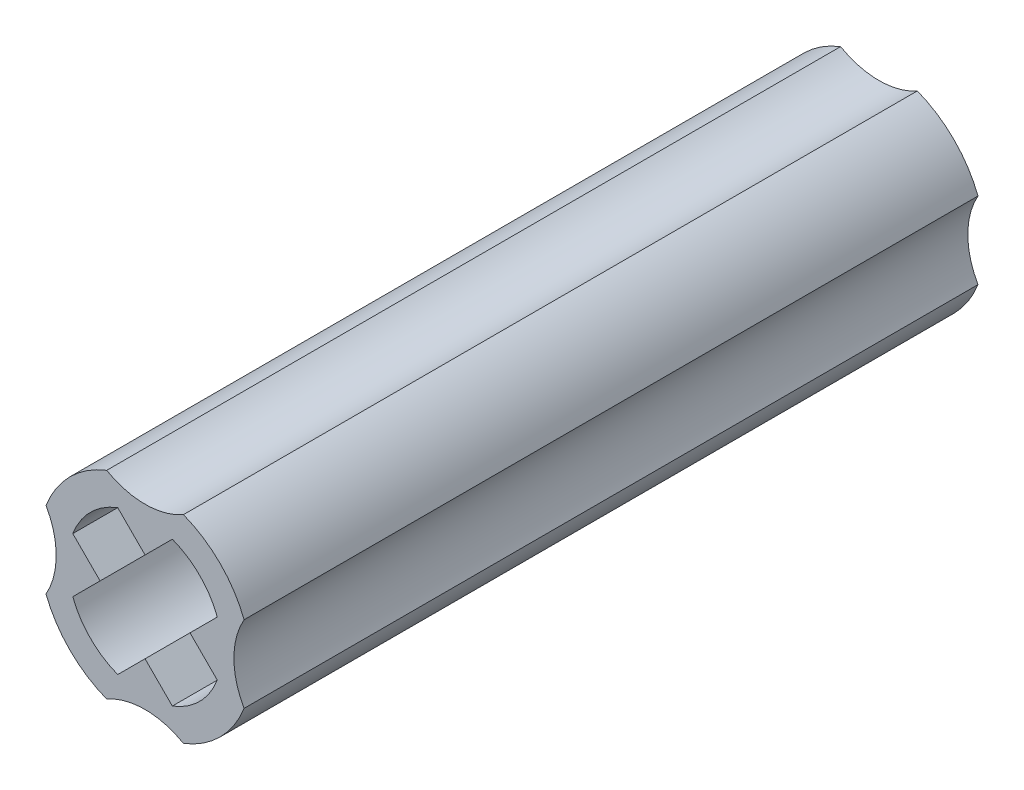
from build123d import *

# Parameters (mm, degrees)
BOSS_EXTRUDE1_DEPTH     = 12.065
CUT_EXTRUDE1_DEPTH      = 13.065
CUT_EXTRUDE1_DEPTH_BACK = 13.065
SKETCH3_R               = 2.54
SKETCH3_R_2             = 1.477926828
BOSS_EXTRUDE2_DEPTH     = 4.1275


with BuildPart() as part:
    # Sketch1 → Boss-Extrude1 (new body, symmetric)
    with BuildSketch(Plane.XY):
        with BuildLine():
            ThreePointArc((-3.256590116, -1.261814988), (-2.469570433, -2.469570433), (-1.261814988, -3.256590116))
            ThreePointArc((-1.261814988, -3.256590116), (0, -2.921), (1.261814988, -3.256590116))
            ThreePointArc((1.261814988, -3.256590116), (2.469570433, -2.469570433), (3.256590116, -1.261814988))
            ThreePointArc((3.256590116, -1.261814988), (2.921, 0), (3.256590116, 1.261814988))
            ThreePointArc((3.256590116, 1.261814988), (2.469570433, 2.469570433), (1.261814988, 3.256590116))
            ThreePointArc((1.261814988, 3.256590116), (0, 2.921), (-1.261814988, 3.256590116))
            ThreePointArc((-1.261814988, 3.256590116), (-2.469570433, 2.469570433), (-3.256590116, 1.261814988))
            ThreePointArc((-3.256590116, 1.261814988), (-2.921, 0), (-3.256590116, -1.261814988))
        make_face()
    extrude(amount=BOSS_EXTRUDE1_DEPTH, both=True)

    # Sketch2 → Cut-Extrude1 (cut, two sides)
    with BuildSketch(Plane.XY) as cut_extrude1_sk:
        with BuildLine():
            Line((-0.898025612, 2.375952441), (0, 1.477926828))
            Line((0, 1.477926828), (0.898025612, 2.375952441))
            ThreePointArc((0.898025612, 2.375952441), (1.796051224, 1.796051224), (2.375952441, 0.898025612))
            Line((2.375952441, 0.898025612), (1.477926828, 0))
            Line((1.477926828, 0), (2.375952441, -0.898025612))
            ThreePointArc((2.375952441, -0.898025612), (1.796051224, -1.796051224), (0.898025612, -2.375952441))
            Line((0.898025612, -2.375952441), (0, -1.477926828))
            Line((0, -1.477926828), (-0.898025612, -2.375952441))
            ThreePointArc((-0.898025612, -2.375952441), (-1.796051224, -1.796051224), (-2.375952441, -0.898025612))
            Line((-2.375952441, -0.898025612), (-1.477926828, 0))
            Line((-1.477926828, 0), (-2.375952441, 0.898025612))
            ThreePointArc((-2.375952441, 0.898025612), (-1.796051224, 1.796051224), (-0.898025612, 2.375952441))
        make_face()
    extrude(amount=CUT_EXTRUDE1_DEPTH, mode=Mode.SUBTRACT)
    extrude(cut_extrude1_sk.sketch, amount=-CUT_EXTRUDE1_DEPTH_BACK, mode=Mode.SUBTRACT)

    # Sketch3 → Boss-Extrude2 (add, symmetric)
    with BuildSketch(Plane.XY):
        Circle(SKETCH3_R)
        Circle(SKETCH3_R_2, mode=Mode.SUBTRACT)
    extrude(amount=BOSS_EXTRUDE2_DEPTH, both=True)


solid = part.part
